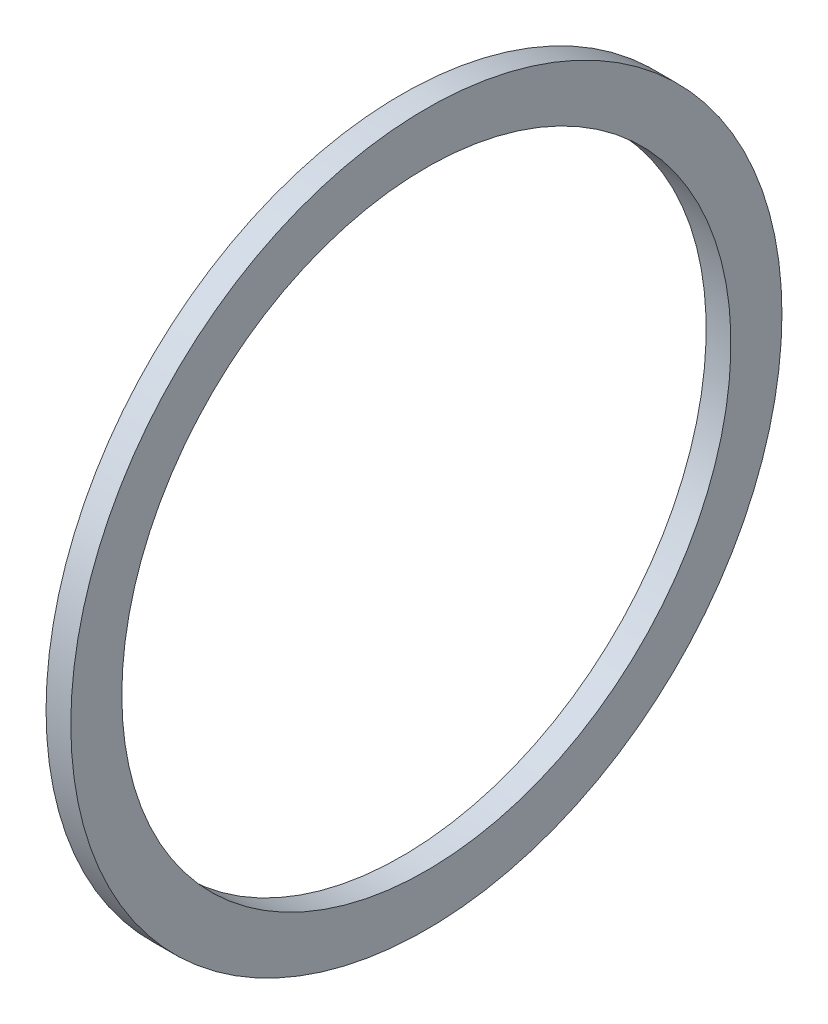
from build123d import *

# Parameters (mm, degrees)
SKETCH1_W = 2.032
SKETCH1_H = 4.191


with BuildPart() as part:
    # Sketch1 → Revolve1 (revolve)
    with BuildSketch(Plane.XY, mode=Mode.PRIVATE) as revolve1_sk:
        with Locations((1.016, -27.1145)):
            Rectangle(SKETCH1_W, SKETCH1_H)
    revolve(revolve1_sk.sketch.rotate(Axis((-43.716580756, 0, 0), (1, 0, 0)), 270), axis=Axis((-43.716580756, 0, 0), (1, 0, 0)))  # turned: the seam where the file's is


solid = part.part
